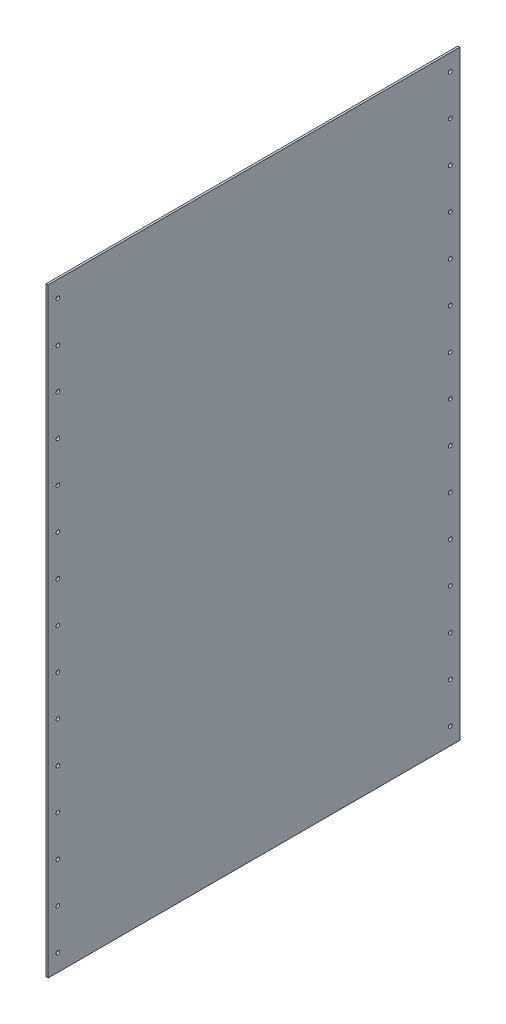
from build123d import *

# Parameters (mm, degrees)
SKETCH1_W           = 609.6
SKETCH1_H           = 889
BOSS_EXTRUDE1_DEPTH = 3
SKETCH2_R           = 2.667
CUT_EXTRUDE1_DEPTH  = 3


with BuildPart() as part:
    # Sketch1 → Boss-Extrude1 (new body)
    with BuildSketch(Plane(origin=(0, 0, 0), x_dir=(0, 0, -1), z_dir=(1, 0, 0))):
        with Locations((304.8, 444.5)):
            Rectangle(SKETCH1_W, SKETCH1_H)
    extrude(amount=BOSS_EXTRUDE1_DEPTH)

    # Sketch2 → Cut-Extrude1 (cut)
    with BuildSketch(Plane(origin=(3, 0, 0), x_dir=(0, 0, -1), z_dir=(1, 0, 0))):
        with Locations((14.2875, 25.4)):
            Circle(SKETCH2_R)
        with Locations((595.3125, 25.4)):
            Circle(SKETCH2_R)
        with Locations((595.3125, 85.344)):
            Circle(SKETCH2_R)
        with Locations((595.3125, 145.288)):
            Circle(SKETCH2_R)
        with Locations((595.3125, 205.232)):
            Circle(SKETCH2_R)
        with Locations((595.3125, 265.176)):
            Circle(SKETCH2_R)
        with Locations((595.3125, 325.12)):
            Circle(SKETCH2_R)
        with Locations((595.3125, 385.064)):
            Circle(SKETCH2_R)
        with Locations((595.3125, 445.008)):
            Circle(SKETCH2_R)
        with Locations((595.3125, 504.952)):
            Circle(SKETCH2_R)
        with Locations((595.3125, 564.896)):
            Circle(SKETCH2_R)
        with Locations((595.3125, 624.84)):
            Circle(SKETCH2_R)
        with Locations((595.3125, 684.784)):
            Circle(SKETCH2_R)
        with Locations((595.3125, 744.728)):
            Circle(SKETCH2_R)
        with Locations((595.3125, 804.672)):
            Circle(SKETCH2_R)
        with Locations((595.3125, 864.616)):
            Circle(SKETCH2_R)
        with Locations((14.2875, 85.344)):
            Circle(SKETCH2_R)
        with Locations((14.2875, 145.288)):
            Circle(SKETCH2_R)
        with Locations((14.2875, 205.232)):
            Circle(SKETCH2_R)
        with Locations((14.2875, 265.176)):
            Circle(SKETCH2_R)
        with Locations((14.2875, 325.12)):
            Circle(SKETCH2_R)
        with Locations((14.2875, 385.064)):
            Circle(SKETCH2_R)
        with Locations((14.2875, 445.008)):
            Circle(SKETCH2_R)
        with Locations((14.2875, 504.952)):
            Circle(SKETCH2_R)
        with Locations((14.2875, 564.896)):
            Circle(SKETCH2_R)
        with Locations((14.2875, 624.84)):
            Circle(SKETCH2_R)
        with Locations((14.2875, 684.784)):
            Circle(SKETCH2_R)
        with Locations((14.2875, 744.728)):
            Circle(SKETCH2_R)
        with Locations((14.2875, 804.672)):
            Circle(SKETCH2_R)
        with Locations((14.2875, 864.616)):
            Circle(SKETCH2_R)
    extrude(amount=-CUT_EXTRUDE1_DEPTH, mode=Mode.SUBTRACT)


solid = part.part
